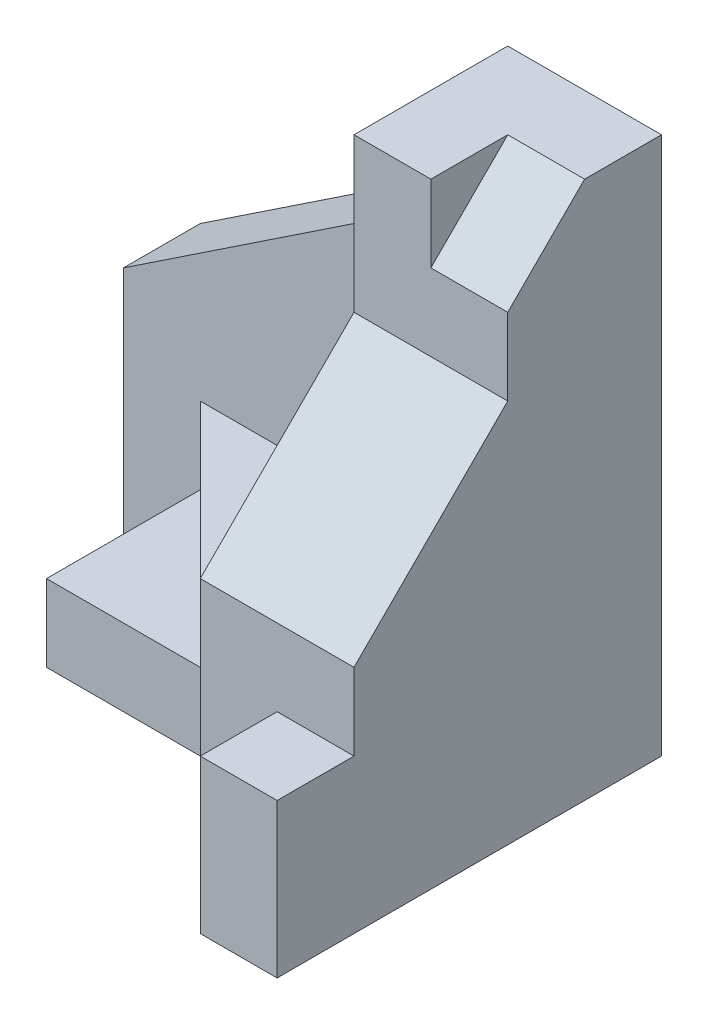
from build123d import *

# Parameters (mm, degrees)
BOSS_EXTRUDE1_DEPTH = 20
CUT_EXTRUDE1_DEPTH  = 10
BOSS_EXTRUDE2_DEPTH = 30
CHAMFER1_SIZE       = 20
CHAMFER2_SIZE       = 20
CHAMFER2_SIZE2      = 30
SKETCH4_W           = 20
SKETCH4_H           = 20
BOSS_EXTRUDE3_DEPTH = 20
CUT_EXTRUDE2_DEPTH  = 10


with BuildPart() as part:
    # Sketch1 → Boss-Extrude1 (new body)
    with BuildSketch(Plane(origin=(0, 0, 0), x_dir=(1, 0, 0), z_dir=(0, 1, 0))):
        Polygon((0, 0), (60, 0), (60, -50), (50, -50), (50, -40), (40, -40), (30, -30), (10, -30), (10, -10), (0, -10), align=None)
    extrude(amount=BOSS_EXTRUDE1_DEPTH)

    # Sketch2 → Cut-Extrude1 (cut)
    with BuildSketch(Plane(origin=(0, 20, 0), x_dir=(1, 0, 0), z_dir=(0, 1, 0))):
        Polygon((30, -30), (10, -10), (10, -30), align=None)
    extrude(amount=-CUT_EXTRUDE1_DEPTH, mode=Mode.SUBTRACT)

    # Sketch3 → Boss-Extrude2 (add)
    with BuildSketch(Plane(origin=(0, 20, 0), x_dir=(1, 0, 0), z_dir=(0, 1, 0))):
        Polygon((0, 0), (60, 0), (60, -40), (40, -40), (40, -10), (10, -10), (0, -10), align=None)
    extrude(amount=BOSS_EXTRUDE2_DEPTH)

    # Chamfer1
    chamfer1_edges = [part.edges().sort_by_distance(p)[0] for p in [
        (50, 50, 40),
    ]]
    chamfer(chamfer1_edges, length=CHAMFER1_SIZE)

    # Chamfer2
    chamfer2_edges = [part.edges().sort_by_distance(p)[0] for p in [
        (0, 50, 5),
    ]]
    chamfer2_side = [part.faces().sort_by_distance(p)[0] for p in [
        (0, 25, 5),
    ]]
    chamfer(chamfer2_edges, length=CHAMFER2_SIZE, length2=CHAMFER2_SIZE2, reference=chamfer2_side[0])

    # Sketch4 → Boss-Extrude3 (add)
    with BuildSketch(Plane(origin=(0, 50, 0), x_dir=(1, 0, 0), z_dir=(0, 1, 0))):
        with Locations((50, -10)):
            Rectangle(SKETCH4_W, SKETCH4_H)
    extrude(amount=BOSS_EXTRUDE3_DEPTH)

    # Sketch5 → Cut-Extrude2 (cut)
    with BuildSketch(Plane(origin=(60, 0, 0), x_dir=(0, 0, -1), z_dir=(1, 0, 0))):
        Polygon((-20, 70), (-10, 70), (-20, 60), align=None)
    extrude(amount=-CUT_EXTRUDE2_DEPTH, mode=Mode.SUBTRACT)


solid = part.part
